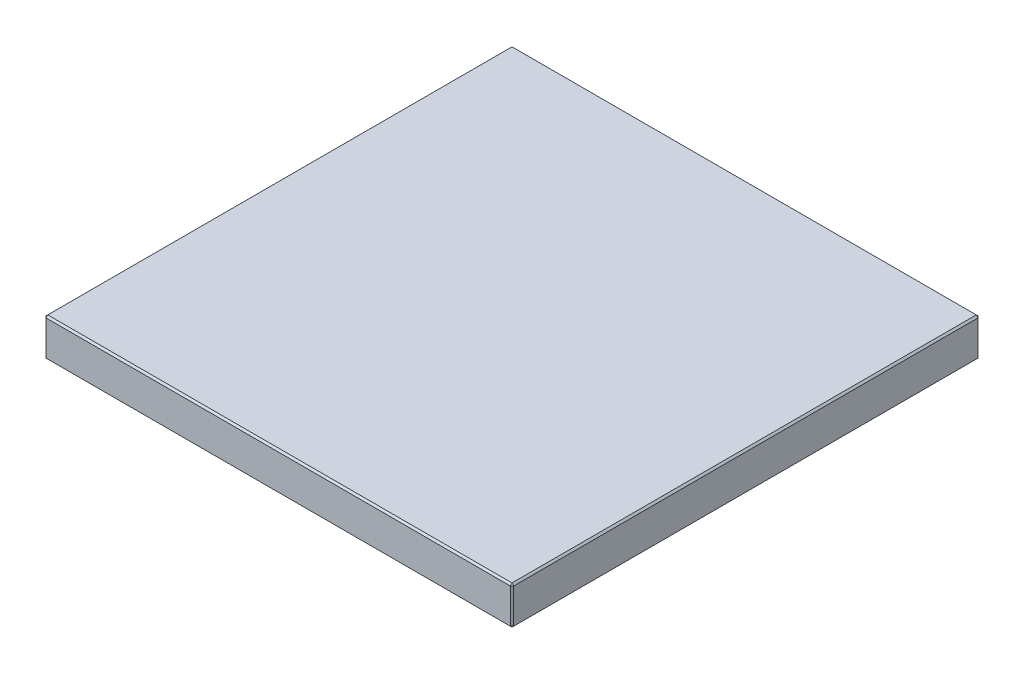
from build123d import *

# Parameters (mm, degrees)
SKETCH1_W           = 26.84
SKETCH1_H           = 26.84
BOSS_EXTRUDE1_DEPTH = 2.2
CHAMFER1_SIZE       = 0.1


with BuildPart() as part:
    # Sketch1 → Boss-Extrude1 (new body)
    with BuildSketch(Plane(origin=(0, 0, 0), x_dir=(1, 0, 0), z_dir=(0, 1, 0))):
        Rectangle(SKETCH1_W, SKETCH1_H)
    extrude(amount=BOSS_EXTRUDE1_DEPTH)

    # Chamfer1
    chamfer1_edges = [part.edges().sort_by_distance(p)[0] for p in [
        (13.42, 2.2, 0),
        (0, 2.2, -13.42),
        (-13.42, 2.2, 0),
        (0, 0, -13.42),
        (13.42, 0, 0),
        (0, 0, 13.42),
        (-13.42, 0, 0),
        (-13.42, 1.1, -13.42),
        (13.42, 1.1, -13.42),
        (13.42, 1.1, 13.42),
        (-13.42, 1.1, 13.42),
        (0, 2.2, 13.42),
    ]]
    chamfer(chamfer1_edges, length=CHAMFER1_SIZE)


solid = part.part
